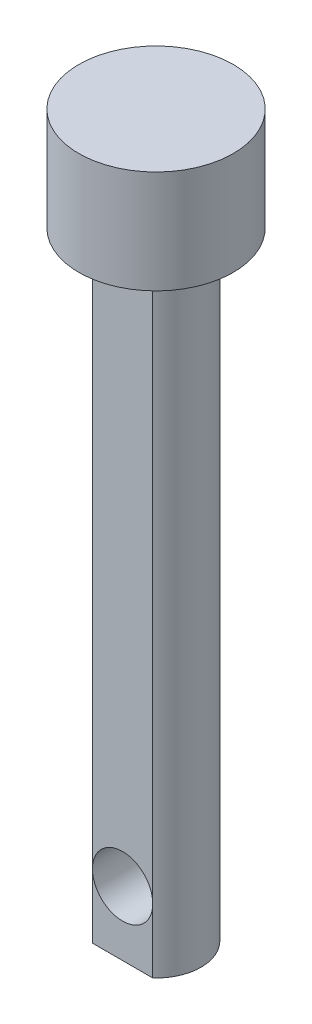
from build123d import *

# Parameters (mm, degrees)
CUT_EXTRUDE1_DEPTH = 24
SKETCH4_R          = 1.171537451
CUT_EXTRUDE2_DEPTH = 5.3


with BuildPart() as part:
    # Sketch2 → Revolve1 (revolve)
    with BuildSketch(Plane(origin=(0, 0, 0), x_dir=(0, 0, -1), z_dir=(1, 0, 0))):
        Polygon((0, 0), (0, 28), (-3, 28), (-3, 24), (-1.75, 24), (-1.75, 0), align=None)
    revolve(axis=Axis((0, 0, 0), (0, 1, 0)))

    # Sketch3 → Cut-Extrude1 (cut)
    with BuildSketch(Plane.XZ):
        with BuildLine():
            Line((-1.171537451, 1.3), (1.171537451, 1.3))
            ThreePointArc((1.171537451, 1.3), (0, 1.75), (-1.171537451, 1.3))
        make_face()
    extrude(amount=-CUT_EXTRUDE1_DEPTH, mode=Mode.SUBTRACT)

    # Sketch4 → Cut-Extrude2 (cut, through all)
    with BuildSketch(Plane.XY.offset(1.3)):
        with Locations((0, 2.5)):
            Circle(SKETCH4_R)
    extrude(amount=-CUT_EXTRUDE2_DEPTH, mode=Mode.SUBTRACT)


solid = part.part
